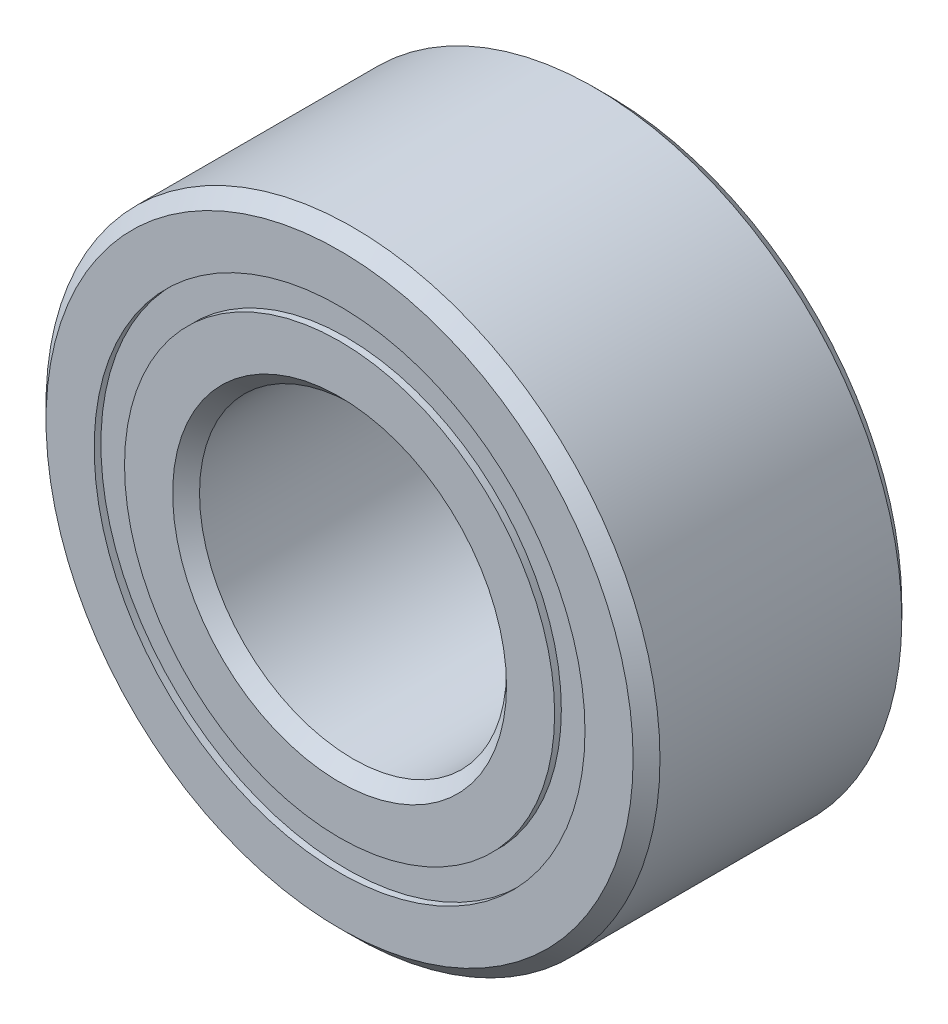
from build123d import *

# Parameters (mm, degrees)
CIRPATTERN1_COUNT = 10
SKETCH5_W         = 0.682768194
SKETCH5_H         = 0.313955164


with BuildPart() as part:
    # Sketch1 → Revolve1 (revolve)
    with BuildSketch(Plane(origin=(0, 0, 0), x_dir=(0, 0, -1), z_dir=(1, 0, 0))):
        with BuildLine():
            Line((1.250442, 3.175), (-1.250442, 3.175))
            Line((-1.250442, 3.175), (-1.38938, 3.036062))
            Line((-1.38938, 3.036062), (-1.38938, 2.538227582))
            Line((-1.38938, 2.538227582), (-0.617502222, 2.538227582))
            ThreePointArc((-0.617502222, 2.538227582), (0, 3.018392806), (0.617502222, 2.538227582))
            Line((0.617502222, 2.538227582), (1.38938, 2.538227582))
            Line((1.38938, 2.538227582), (1.38938, 3.036062))
            Line((1.38938, 3.036062), (1.250442, 3.175))
        make_face()
    revolve(axis=Axis((0, 0, 1.38938), (0, 0, -1)))


with BuildPart() as body_2:
    # Sketch3 → Revolve3 (revolve)
    with BuildSketch(Plane(origin=(0, 0, 0), x_dir=(0, 0, -1), z_dir=(1, 0, 0))):
        with BuildLine():
            Line((-0.617502222, 2.224272418), (-1.38938, 2.224272418))
            Line((-1.38938, 2.224272418), (-1.38938, 1.726438))
            Line((-1.38938, 1.726438), (-1.250442, 1.5875))
            Line((-1.250442, 1.5875), (1.250442, 1.5875))
            Line((1.250442, 1.5875), (1.38938, 1.726438))
            Line((1.38938, 1.726438), (1.38938, 2.224272418))
            Line((1.38938, 2.224272418), (0.617502222, 2.224272418))
            ThreePointArc((0.617502222, 2.224272418), (0, 1.744107194), (-0.617502222, 2.224272418))
        make_face()
    revolve(axis=Axis((0, 0, 1.38938), (0, 0, -1)))


with BuildPart() as body_3:
    # Sketch4 → Revolve4 (revolve)
    with BuildSketch(Plane(origin=(0, 0, 0), x_dir=(0, 0, -1), z_dir=(1, 0, 0))):
        with BuildLine():
            Line((-0.637142806, 2.38125), (0.637142806, 2.38125))
            ThreePointArc((0.637142806, 2.38125), (0, 3.018392806), (-0.637142806, 2.38125))
        make_face()
    revolve(axis=Axis((0, 2.38125, 0.637142806), (0, 0, -1)))


with BuildPart() as cirpattern1_1:
    # CirPattern1: pattern copy
    add(body_3.part.rotate(Axis((0, 0, -1.38938), (0, 0, 1)), 1 * 360 / CIRPATTERN1_COUNT))


with BuildPart() as cirpattern1_2:
    # CirPattern1: pattern copy
    add(body_3.part.rotate(Axis((0, 0, -1.38938), (0, 0, 1)), 2 * 360 / CIRPATTERN1_COUNT))


with BuildPart() as cirpattern1_3:
    # CirPattern1: pattern copy
    add(body_3.part.rotate(Axis((0, 0, -1.38938), (0, 0, 1)), 3 * 360 / CIRPATTERN1_COUNT))


with BuildPart() as cirpattern1_4:
    # CirPattern1: pattern copy
    add(body_3.part.rotate(Axis((0, 0, -1.38938), (0, 0, 1)), 4 * 360 / CIRPATTERN1_COUNT))


with BuildPart() as cirpattern1_5:
    # CirPattern1: pattern copy
    add(body_3.part.rotate(Axis((0, 0, -1.38938), (0, 0, 1)), 5 * 360 / CIRPATTERN1_COUNT))


with BuildPart() as cirpattern1_6:
    # CirPattern1: pattern copy
    add(body_3.part.rotate(Axis((0, 0, -1.38938), (0, 0, 1)), 6 * 360 / CIRPATTERN1_COUNT))


with BuildPart() as cirpattern1_7:
    # CirPattern1: pattern copy
    add(body_3.part.rotate(Axis((0, 0, -1.38938), (0, 0, 1)), 7 * 360 / CIRPATTERN1_COUNT))


with BuildPart() as cirpattern1_8:
    # CirPattern1: pattern copy
    add(body_3.part.rotate(Axis((0, 0, -1.38938), (0, 0, 1)), 8 * 360 / CIRPATTERN1_COUNT))


with BuildPart() as cirpattern1_9:
    # CirPattern1: pattern copy
    add(body_3.part.rotate(Axis((0, 0, -1.38938), (0, 0, 1)), 9 * 360 / CIRPATTERN1_COUNT))


with BuildPart() as body_13:
    # Sketch5 → Revolve5 (revolve)
    with BuildSketch(Plane(origin=(0, 0, 0), x_dir=(0, 0, -1), z_dir=(1, 0, 0))):
        with Locations((-0.978526903, 2.38125)):
            Rectangle(SKETCH5_W, SKETCH5_H)
        with Locations((0.978526903, 2.38125)):
            Rectangle(SKETCH5_W, SKETCH5_H)
    revolve(axis=Axis((0, 0, 1.38938), (0, 0, -1)))


solid = Compound([part.part, body_2.part, body_3.part, cirpattern1_1.part, cirpattern1_2.part, cirpattern1_3.part, cirpattern1_4.part, cirpattern1_5.part, cirpattern1_6.part, cirpattern1_7.part, cirpattern1_8.part, cirpattern1_9.part, body_13.part])
